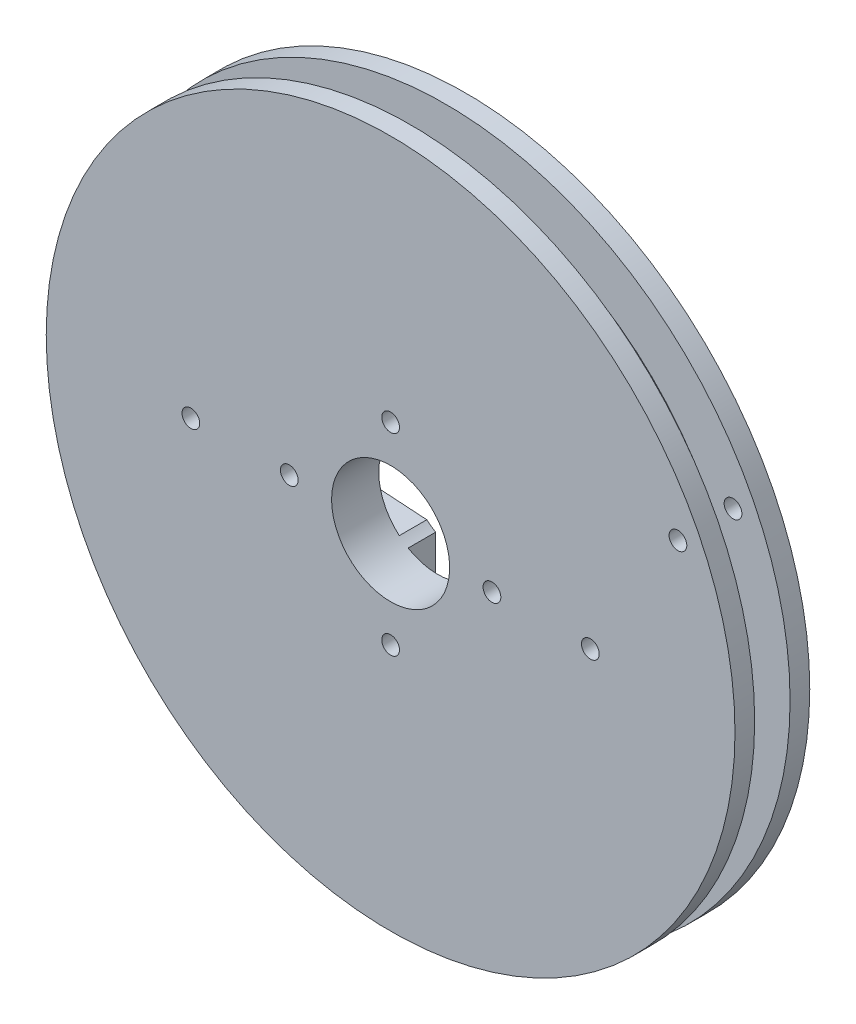
from build123d import *

# Parameters (mm, degrees)
SKETCH1_R           = 19.05
BOSS_EXTRUDE1_DEPTH = 1.143
SKETCH2_R           = 22.225
BOSS_EXTRUDE2_DEPTH = 1.27
SKETCH3_R           = 3.556
CUT_EXTRUDE1_DEPTH  = 5.826
SKETCH4_R           = 0.5715
CUT_EXTRUDE3_DEPTH  = 5.826
SKETCH5_R           = 0.5715
CUT_EXTRUDE4_DEPTH  = 5.826
CUT_EXTRUDE5_DEPTH  = 1.778
SKETCH10_R          = 0.5715
CUT_EXTRUDE6_DEPTH  = 5.826
SKETCH11_R          = 3.81
CUT_EXTRUDE7_DEPTH  = 5.826


with BuildPart() as part:
    # Sketch1 → Boss-Extrude1 (new body, symmetric)
    with BuildSketch(Plane.XY):
        Circle(SKETCH1_R)
    extrude(amount=BOSS_EXTRUDE1_DEPTH, both=True)

    # Sketch2 → Boss-Extrude2 (add)
    with BuildSketch(Plane.XY.offset(1.143)):
        Circle(SKETCH2_R)
    boss_extrude2 = extrude(amount=BOSS_EXTRUDE2_DEPTH)

    # Mirror1: Boss-Extrude2 across plane
    add(boss_extrude2.mirror(Plane.XY))

    # Sketch3 → Cut-Extrude1 (cut, through all)
    with BuildSketch(Plane(origin=(0, 0, -2.413), x_dir=(-1, 0, 0), z_dir=(0, 0, -1))):
        Circle(SKETCH3_R)
    extrude(amount=-CUT_EXTRUDE1_DEPTH, mode=Mode.SUBTRACT)

    # Sketch4 → Cut-Extrude3 (cut, through all)
    with BuildSketch(Plane(origin=(0, 0, -2.413), x_dir=(-1, 0, 0), z_dir=(0, 0, -1))):
        with Locations((12.8905, 0)):
            Circle(SKETCH4_R)
        with Locations((6.5405, 0)):
            Circle(SKETCH4_R)
        with Locations((-12.8905, 0)):
            Circle(SKETCH4_R)
        with Locations((-6.5405, 0)):
            Circle(SKETCH4_R)
    extrude(amount=-CUT_EXTRUDE3_DEPTH, mode=Mode.SUBTRACT)

    # Sketch5 → Cut-Extrude4 (cut, through all)
    with BuildSketch(Plane(origin=(0, 0, -2.413), x_dir=(-1, 0, 0), z_dir=(0, 0, -1))):
        with Locations((-18.542, 8.89)):
            Circle(SKETCH5_R)
    extrude(amount=-CUT_EXTRUDE4_DEPTH, mode=Mode.SUBTRACT)

    # Sketch7 → Cut-Extrude5 (cut)
    with BuildSketch(Plane(origin=(0, 0, -2.413), x_dir=(-1, 0, 0), z_dir=(0, 0, -1))):
        with BuildLine():
            Line((-1.9177, 3.6195), (-1.9177, 6.4262))
            ThreePointArc((-1.9177, 6.4262), (0, 8.3439), (1.9177, 6.4262))
            Line((1.9177, 6.4262), (1.9177, 2.921))
            Line((1.9177, 2.921), (14.672772863, 2.0955))
            ThreePointArc((14.672772863, 2.0955), (16.383, 0), (14.672772863, -2.0955))
            Line((14.672772863, -2.0955), (1.9177, -2.921))
            Line((1.9177, -2.921), (1.9177, -6.4262))
            ThreePointArc((1.9177, -6.4262), (0, -8.3439), (-1.9177, -6.4262))
            Line((-1.9177, -6.4262), (-1.9177, -3.6195))
            Line((-1.9177, -3.6195), (-16.902805323, -2.0955))
            ThreePointArc((-16.902805323, -2.0955), (-18.796, 0), (-16.902805323, 2.0955))
            Line((-16.902805323, 2.0955), (-1.9177, 3.6195))
        make_face()
    extrude(amount=-CUT_EXTRUDE5_DEPTH, mode=Mode.SUBTRACT)

    # Sketch10 → Cut-Extrude6 (cut, through all)
    with BuildSketch(Plane(origin=(0, 0, -2.413), x_dir=(-1, 0, 0), z_dir=(0, 0, -1))):
        with Locations((0, -6.223)):
            Circle(SKETCH10_R)
        with Locations((0, 6.223)):
            Circle(SKETCH10_R)
    extrude(amount=-CUT_EXTRUDE6_DEPTH, mode=Mode.SUBTRACT)

    # Sketch11 → Cut-Extrude7 (cut, through all)
    with BuildSketch(Plane(origin=(0, 0, -2.413), x_dir=(-1, 0, 0), z_dir=(0, 0, -1))):
        Circle(SKETCH11_R)
    extrude(amount=-CUT_EXTRUDE7_DEPTH, mode=Mode.SUBTRACT)


solid = part.part
